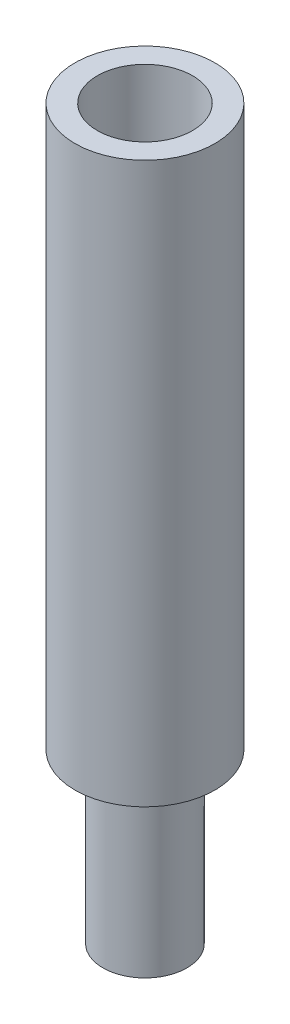
from build123d import *

# Parameters (mm, degrees)
ESQUISSE1_R             = 2.5
BOSS_EXTRU_1_DEPTH      = 20
ESQUISSE2_R             = 1.5
BOSS_EXTRU_2_DEPTH      = 6
ESQUISSE6_R             = 1.7
ENL_V_MAT_EXTRU_1_DEPTH = 10


with BuildPart() as part:
    # Esquisse1 → Boss.-Extru.1 (new body)
    with BuildSketch(Plane(origin=(0, 0, 0), x_dir=(1, 0, 0), z_dir=(0, 1, 0))):
        Circle(ESQUISSE1_R)
    extrude(amount=BOSS_EXTRU_1_DEPTH)

    # Esquisse2 → Boss.-Extru.2 (add)
    with BuildSketch(Plane.XZ):
        Circle(ESQUISSE2_R)
    extrude(amount=BOSS_EXTRU_2_DEPTH)

    # Esquisse6 → Enlèv. mat.-Extru.1 (cut)
    with BuildSketch(Plane(origin=(0, 20, 0), x_dir=(1, 0, 0), z_dir=(0, 1, 0))):
        Circle(ESQUISSE6_R)
    extrude(amount=-ENL_V_MAT_EXTRU_1_DEPTH, mode=Mode.SUBTRACT)


solid = part.part
